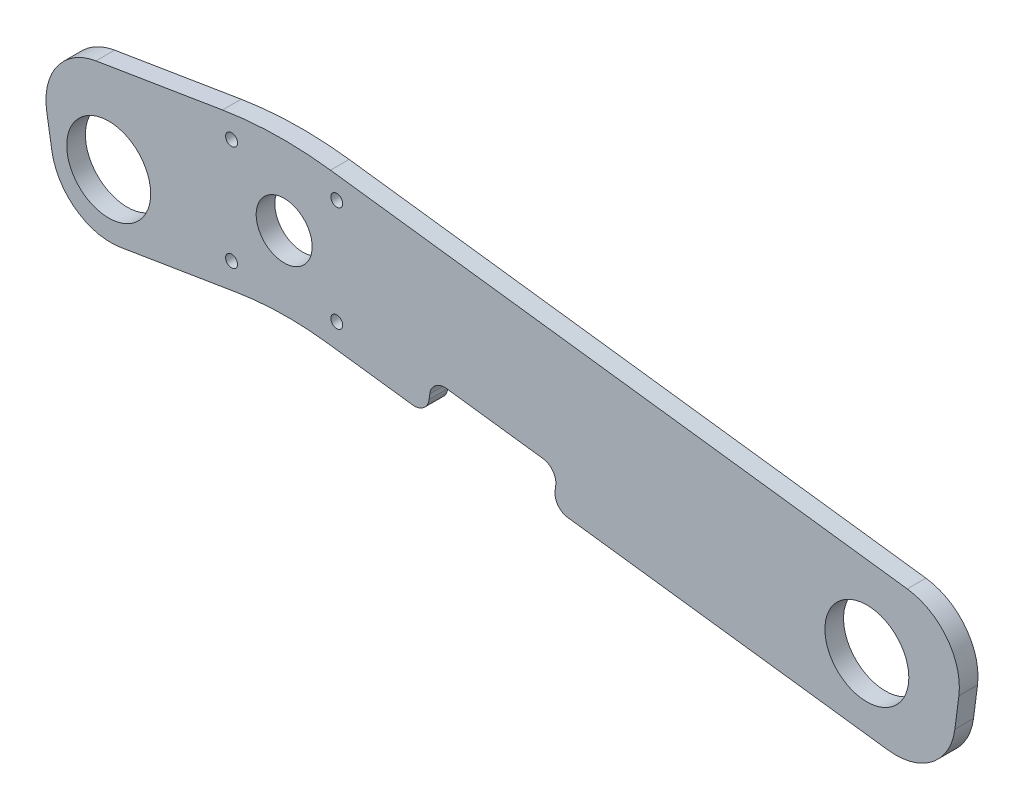
from build123d import *

# Parameters (mm, degrees)
BOSS_EXTRUDE4_DEPTH = 6.35
SKETCH8_R           = 14.2875
SKETCH8_R_2         = 2.032
SKETCH8_R_3         = 9.525
CUT_EXTRUDE7_DEPTH  = 6.35
FILLET1_R           = 127
FILLET2_R           = 20.32
FILLET3_R           = 20.32
FILLET4_R           = 20.32
FILLET5_R           = 20.32
FILLET6_R           = 106.68
FILLET15_R          = 5.08
FILLET16_R          = 5.08
FILLET17_R          = 5.08
FILLET18_R          = 5.08


with BuildPart() as part:
    # Sketch6 → Boss-Extrude4 (new body)
    with BuildSketch(Plane.XY):
        Polygon((-430.595798314, -65.46403997), (-349.134252231, -52.10293935), (-114.184252231, -82.35181316), (-120.72454927, -133.15181316), (-347.342471816, -103.975661033), (-422.26372086, -116.26403997), align=None)
    extrude(amount=BOSS_EXTRUDE4_DEPTH)

    # Sketch8 → Cut-Extrude7 (cut)
    with BuildSketch(Plane.XY.offset(6.35)):
        with Locations((-406.219595957, -92.055134427)):
            Circle(SKETCH8_R)
        with Locations((-148.100562805, -105.64860282)):
            Circle(SKETCH8_R)
        with Locations((-364.383471272, -62.287100468)):
            Circle(SKETCH8_R_2)
        with Locations((-364.384308881, -98.101100468)):
            Circle(SKETCH8_R_2)
        with Locations((-328.570308884, -98.10061012)):
            Circle(SKETCH8_R_2)
        with Locations((-328.569471275, -62.28661013)):
            Circle(SKETCH8_R_2)
        with Locations((-346.476890078, -80.193855294)):
            Circle(SKETCH8_R_3)
        Polygon((-254.89844174, -115.877460566), (-253.367356027, -103.985163664), (-296.240101937, -98.465468917), (-297.77118765, -110.357765819), align=None)
    extrude(amount=-CUT_EXTRUDE7_DEPTH, mode=Mode.SUBTRACT)

    # Fillet1
    fillet1_edges = [part.edges().sort_by_distance(p)[0] for p in [
        (-349.134252231, -52.10293935, 3.175),
    ]]
    fillet(fillet1_edges, radius=FILLET1_R)

    # Fillet2
    fillet2_edges = [part.edges().sort_by_distance(p)[0] for p in [
        (-430.595798314, -65.46403997, 3.175),
    ]]
    fillet(fillet2_edges, radius=FILLET2_R)

    # Fillet3
    fillet3_edges = [part.edges().sort_by_distance(p)[0] for p in [
        (-422.26372086, -116.26403997, 3.175),
    ]]
    fillet(fillet3_edges, radius=FILLET3_R)

    # Fillet4
    fillet4_edges = [part.edges().sort_by_distance(p)[0] for p in [
        (-114.184252231, -82.35181316, 3.175),
    ]]
    fillet(fillet4_edges, radius=FILLET4_R)

    # Fillet5
    fillet5_edges = [part.edges().sort_by_distance(p)[0] for p in [
        (-120.72454927, -133.15181316, 3.175),
    ]]
    fillet(fillet5_edges, radius=FILLET5_R)

    # Fillet6
    fillet6_edges = [part.edges().sort_by_distance(p)[0] for p in [
        (-347.342471816, -103.975661033, 3.175),
    ]]
    fillet(fillet6_edges, radius=FILLET6_R)

    # Fillet15
    fillet15_edges = [part.edges().sort_by_distance(p)[0] for p in [
        (-254.89844174, -115.877460566, 3.175),
    ]]
    fillet(fillet15_edges, radius=FILLET15_R)

    # Fillet16
    fillet16_edges = [part.edges().sort_by_distance(p)[0] for p in [
        (-297.77118765, -110.357765819, 3.175),
    ]]
    fillet(fillet16_edges, radius=FILLET16_R)

    # Fillet17
    fillet17_edges = [part.edges().sort_by_distance(p)[0] for p in [
        (-296.240101937, -98.465468917, 3.175),
    ]]
    fillet(fillet17_edges, radius=FILLET17_R)

    # Fillet18
    fillet18_edges = [part.edges().sort_by_distance(p)[0] for p in [
        (-253.367356027, -103.985163664, 3.175),
    ]]
    fillet(fillet18_edges, radius=FILLET18_R)


solid = part.part
